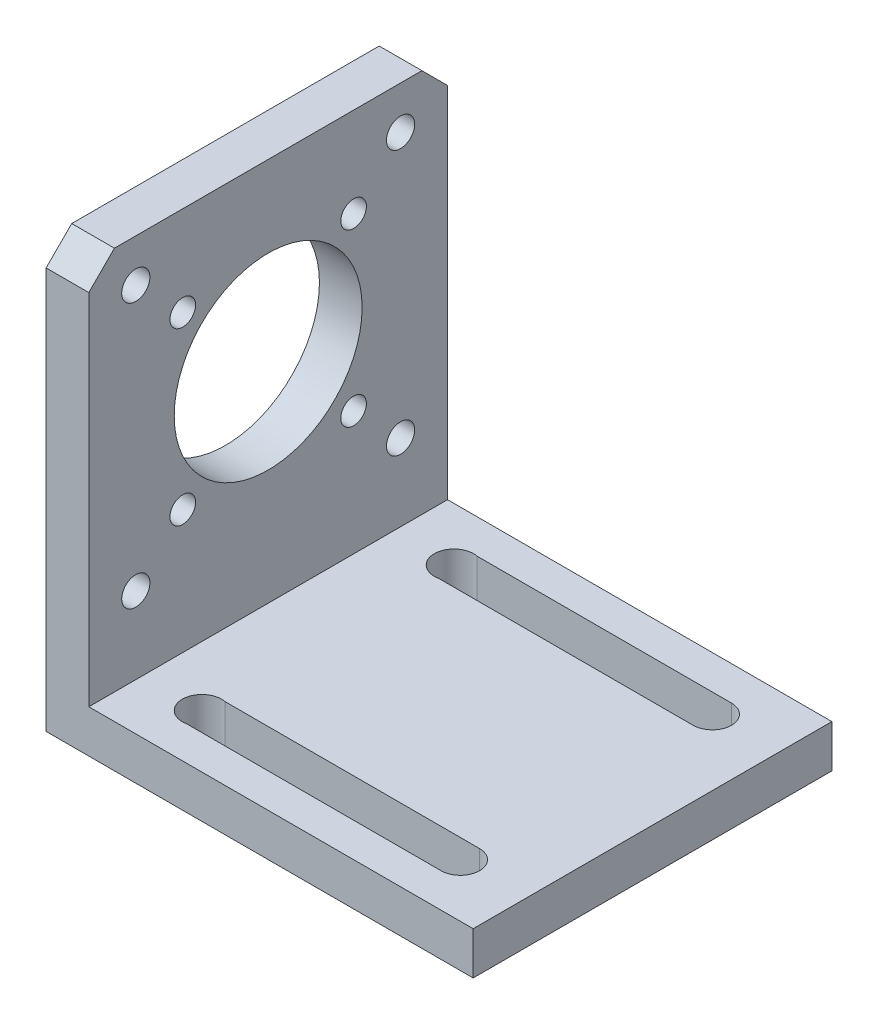
from build123d import *

# Parameters (mm, degrees)
SKETCH1_W           = 50
SKETCH1_H           = 42
BOSS_EXTRUDE1_DEPTH = 5
SKETCH2_W           = 5
SKETCH2_H           = 42
BOSS_EXTRUDE2_DEPTH = 45
CUT_EXTRUDE1_DEPTH  = 45
CUT_EXTRUDE3_DEPTH  = 6
SKETCH7_R           = 11
SKETCH7_R_2         = 1.65
SKETCH7_R_3         = 1.5
CUT_EXTRUDE4_DEPTH  = 6


with BuildPart() as part:
    # Sketch1 → Boss-Extrude1 (new body)
    with BuildSketch(Plane(origin=(0, 0, 0), x_dir=(1, 0, 0), z_dir=(0, 1, 0))):
        with Locations((25, 21)):
            Rectangle(SKETCH1_W, SKETCH1_H)
    extrude(amount=BOSS_EXTRUDE1_DEPTH)

    # Sketch2 → Boss-Extrude2 (add)
    with BuildSketch(Plane(origin=(0, 5, 0), x_dir=(1, 0, 0), z_dir=(0, 1, 0))):
        with Locations((2.5, 21)):
            Rectangle(SKETCH2_W, SKETCH2_H)
    extrude(amount=BOSS_EXTRUDE2_DEPTH)

    # Sketch3 → Cut-Extrude1 (cut)
    with BuildSketch(Plane(origin=(5, 0, 0), x_dir=(0, 0, -1), z_dir=(1, 0, 0))):
        Polygon((0, 47), (3, 50), (0, 50), align=None)
        Polygon((42, 50), (39, 50), (42, 47), align=None)
    extrude(amount=-CUT_EXTRUDE1_DEPTH, mode=Mode.SUBTRACT)

    # Sketch4 → Cut-Extrude3 (cut, through all)
    with BuildSketch(Plane(origin=(0, 5, 0), x_dir=(1, 0, 0), z_dir=(0, 1, 0))):
        with BuildLine():
            Line((12.471581484, 8.5), (42.25, 8.5))
            ThreePointArc((42.25, 8.5), (44.5, 6.25), (42.25, 4))
            Line((42.25, 4), (12.471581484, 4))
            ThreePointArc((12.471581484, 4), (9.701111334, 6.25), (12.471581484, 8.5))
        make_face()
        with BuildLine():
            Line((12.471581484, 38), (42.25, 38))
            ThreePointArc((42.25, 38), (44.5, 35.75), (42.25, 33.5))
            Line((42.25, 33.5), (12.471581484, 33.5))
            ThreePointArc((12.471581484, 33.5), (9.701111334, 35.75), (12.471581484, 38))
        make_face()
    extrude(amount=-CUT_EXTRUDE3_DEPTH, mode=Mode.SUBTRACT)

    # Sketch7 → Cut-Extrude4 (cut, through all)
    with BuildSketch(Plane(origin=(5, 0, 0), x_dir=(0, 0, -1), z_dir=(1, 0, 0))):
        with Locations((21, 29.5)):
            Circle(SKETCH7_R)
        with Locations((5.5, 45)):
            Circle(SKETCH7_R_2)
        with Locations((31, 39.5)):
            Circle(SKETCH7_R_3)
        with Locations((5.5, 14)):
            Circle(SKETCH7_R_2)
        with Locations((31, 19.5)):
            Circle(SKETCH7_R_3)
        with Locations((36.5, 14)):
            Circle(SKETCH7_R_2)
        with Locations((11, 19.5)):
            Circle(SKETCH7_R_3)
        with Locations((11, 39.5)):
            Circle(SKETCH7_R_3)
        with Locations((36.5, 45)):
            Circle(SKETCH7_R_2)
    extrude(amount=-CUT_EXTRUDE4_DEPTH, mode=Mode.SUBTRACT)


solid = part.part
